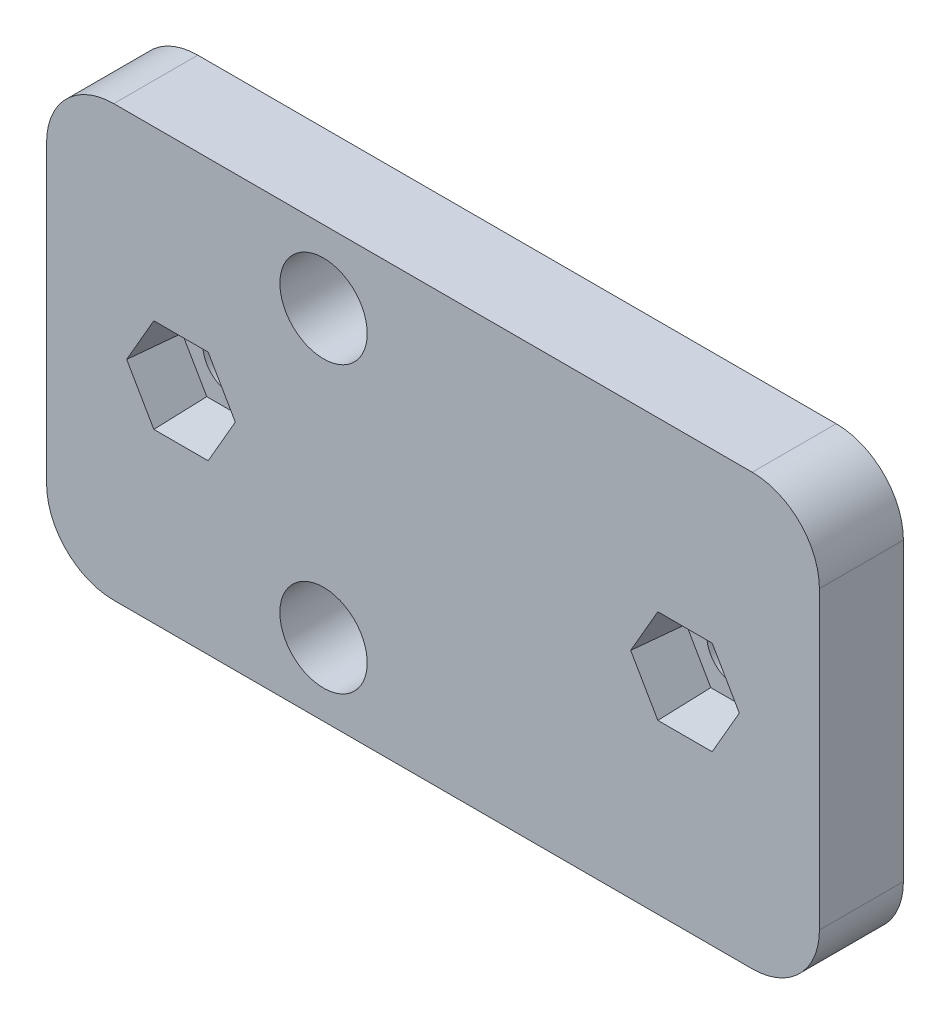
from build123d import *

# Parameters (mm, degrees)
ESQUISSE1_W             = 46
ESQUISSE1_H             = 25.6
ESQUISSE1_R             = 1.7
ESQUISSE1_R_2           = 2.6
BOSS_EXTRU_1_DEPTH      = 5
ENL_V_MAT_EXTRU_2_DEPTH = 3
ENL_V_MAT_EXTRU_2_TAPER = 5
CONG_1_R                = 4


with BuildPart() as part:
    # Esquisse1 → Boss.-Extru.1 (new body)
    with BuildSketch(Plane.XY):
        with Locations((15.830047476, 0)):
            Rectangle(ESQUISSE1_W, ESQUISSE1_H)
        with Locations((0.830047476, 0)):
            Circle(ESQUISSE1_R, mode=Mode.SUBTRACT)
        with Locations((9.315328851, 8.485281374)):
            Circle(ESQUISSE1_R_2, mode=Mode.SUBTRACT)
        with Locations((9.315328851, -8.485281374)):
            Circle(ESQUISSE1_R_2, mode=Mode.SUBTRACT)
        with Locations((30.830047476, 0)):
            Circle(ESQUISSE1_R, mode=Mode.SUBTRACT)
    extrude(amount=BOSS_EXTRU_1_DEPTH)

    # Esquisse3 → Enlèv. mat.-Extru.2 (cut)
    with BuildSketch(Plane.XY.offset(5)):
        Polygon((4.063208984, 0), (2.44662823, 2.8), (-0.786533277, 2.8), (-2.403114031, 0), (-0.786533277, -2.8), (2.44662823, -2.8), align=None)
        Polygon((34.063208984, 0), (32.44662823, 2.8), (29.213466723, 2.8), (27.596885969, 0), (29.213466723, -2.8), (32.44662823, -2.8), align=None)
    extrude(amount=-ENL_V_MAT_EXTRU_2_DEPTH, taper=ENL_V_MAT_EXTRU_2_TAPER, mode=Mode.SUBTRACT)

    # Congé1
    cong_1_edges = [part.edges().sort_by_distance(p)[0] for p in [
        (38.830047476, -12.8, 2.5),
        (-7.169952524, -12.8, 2.5),
        (-7.169952524, 12.8, 2.5),
        (38.830047476, 12.8, 2.5),
    ]]
    fillet(cong_1_edges, radius=CONG_1_R)


solid = part.part
